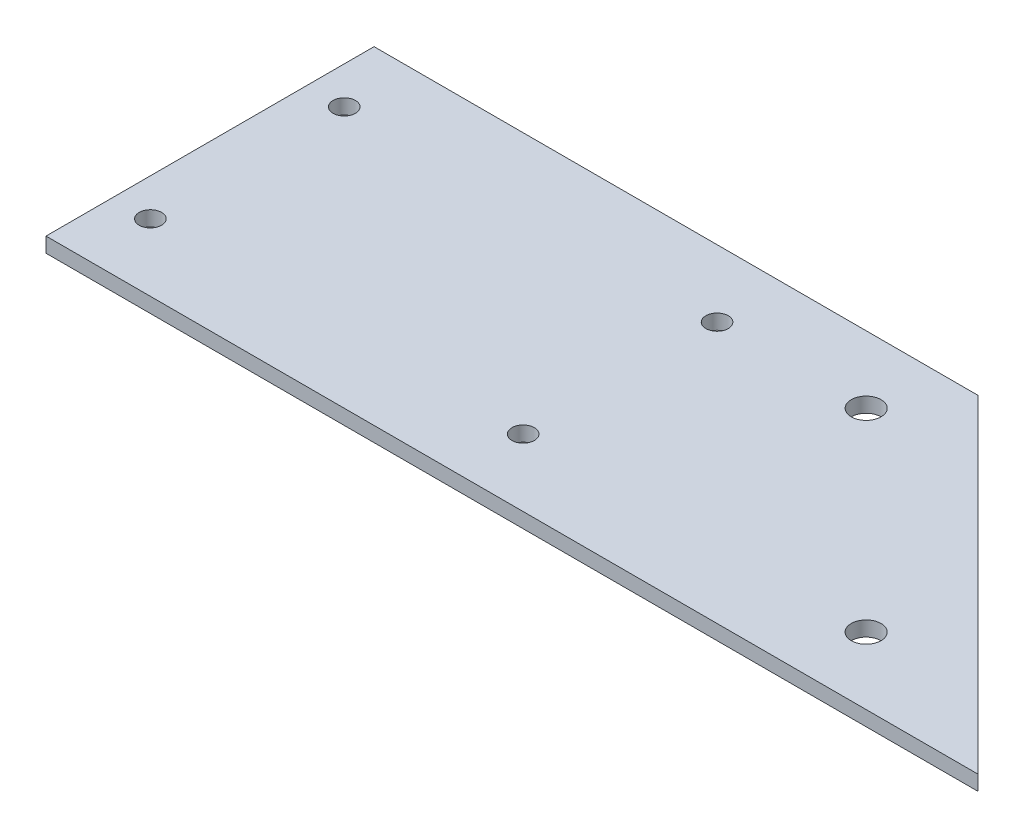
from build123d import *

# Parameters (mm, degrees)
SKETCH1_R           = 1.5
SKETCH1_R_2         = 2
BOSS_EXTRUDE1_DEPTH = 2


with BuildPart() as part:
    # Sketch1 → Boss-Extrude1 (new body)
    with BuildSketch(Plane(origin=(0, 0, 0), x_dir=(1, 0, 0), z_dir=(0, 1, 0))):
        Polygon((81, 44), (125, 0), (0, 0), (0, 44), align=None)
        with Locations(Location((5, 35, 0), (0, 0, 270))):  # turned: the seam where the file's is
            Circle(SKETCH1_R, mode=Mode.SUBTRACT)
        with Locations(Location((5, 9, 0), (0, 0, 270))):  # turned: the seam where the file's is
            Circle(SKETCH1_R, mode=Mode.SUBTRACT)
        with Locations(Location((55, 9, 0), (0, 0, 270))):  # turned: the seam where the file's is
            Circle(SKETCH1_R, mode=Mode.SUBTRACT)
        with Locations(Location((55, 35, 0), (0, 0, 270))):  # turned: the seam where the file's is
            Circle(SKETCH1_R, mode=Mode.SUBTRACT)
        with Locations(Location((75, 35, 0), (0, 0, 270))):  # turned: the seam where the file's is
            Circle(SKETCH1_R_2, mode=Mode.SUBTRACT)
        with Locations(Location((101, 9, 0), (0, 0, 270))):  # turned: the seam where the file's is
            Circle(SKETCH1_R_2, mode=Mode.SUBTRACT)
    extrude(amount=BOSS_EXTRUDE1_DEPTH)


solid = part.part
